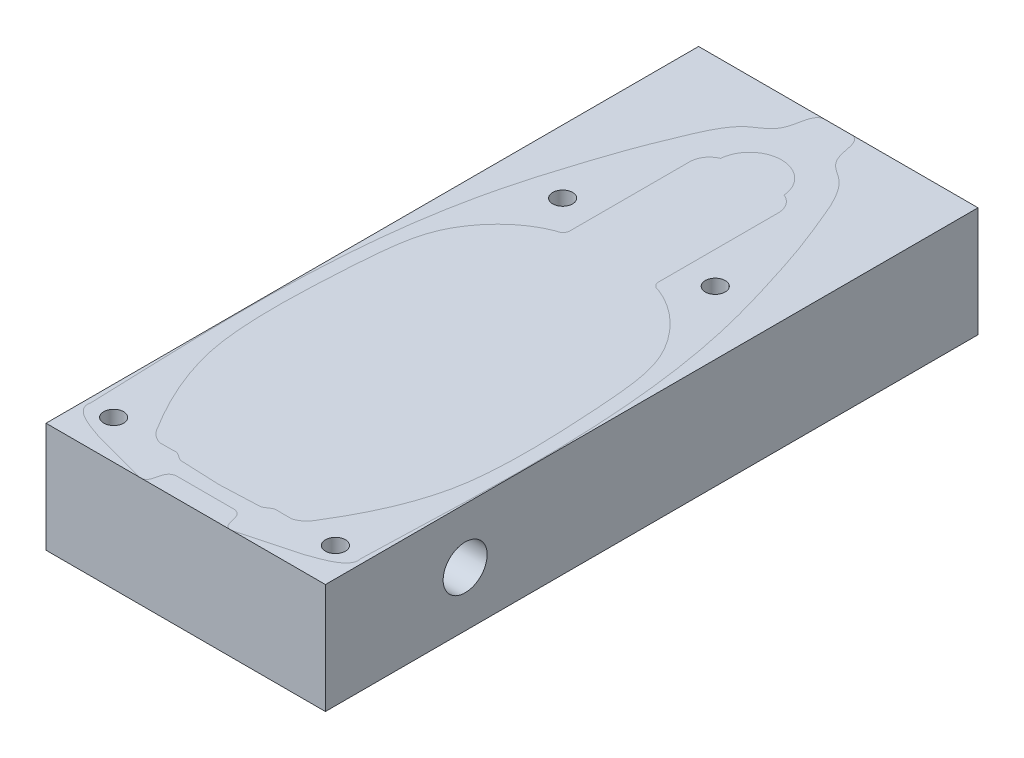
from build123d import *

# Parameters (mm, degrees)
SKETCH1_R           = 3.624738262
BOSS_EXTRUDE1_DEPTH = 39.99992
CUT_EXTRUDE1_DEPTH  = 12.7
SKETCH2_5_R         = 8
CUT_EXTRUDE2_DEPTH  = 32
SKETCH2_6_R         = 8
CUT_EXTRUDE3_DEPTH  = 102.6
CUT_EXTRUDE4_DEPTH  = 6.35


with BuildPart() as part:
    # Sketch1 → Boss-Extrude1 (new body)
    with BuildSketch(Plane(origin=(0, 0, 0), x_dir=(1, 0, 0), z_dir=(0, 1, 0))):
        with BuildLine():
            add(Edge.make_bspline(
                [(-5.102919532, 217.442534033), (-6.772186373, 217.270668093), (-8.307034074, 214.419403759), (-8.818468152, 209.809743179), (-10.450311171, 205.542036855), (-13.988349159, 202.878315551), (-17.135052097, 200.878659029), (-21.922509673, 195.198487494), (-25.105344828, 187.023597167), (-30.549633993, 174.097860197), (-35.960133295, 157.773461946), (-44.738307888, 128.665983431), (-52.530859765, 73.643219076), (-50.064387697, 26.1166546), (-49.077139095, -5.292317253)],
                knots=[0.002425274, 0.002425274, 0.002425274, 0.002425274, 0.022096851, 0.039559354, 0.063258598, 0.077264421, 0.095563037, 0.110967211, 0.171488249, 0.206517367, 0.29130997, 0.391743327, 0.59645674, 1, 1, 1, 1], degree=3))
            Line((-5.102919532, 217.442534033), (-50.8, 217.442534033))
            Line((-50.8, 217.442534033), (-50.8, -19.841855411))
            Line((-50.8, -19.841855411), (-16.3294738, -19.841855411))
            add(Edge.make_bspline(
                [(-18.385240054, -19.414944059), (-17.545507284, -19.711304849), (-16.873048404, -19.841855249), (-16.3294738, -19.841855411)],
                knots=[0, 0, 0, 0, 0.124003814, 0.124003814, 0.124003814, 0.124003814], degree=3))
            add(Edge.make_bspline(
                [(-37.41909493, -14.341890116), (-18.385240054, -19.414944059)],
                knots=[0, 0, 1, 1], degree=1))
            add(Edge.make_bspline(
                [(-49.077139095, -5.292317253), (-50.568888317, -10.940069386), (-38.832871978, -13.504300857), (-37.41909493, -14.341890116)],
                knots=[0, 0, 0, 0, 1, 1, 1, 1], degree=3))
        make_face()
        with BuildLine():
            Line((50.8, 217.442534033), (5.102919532, 217.442534033))
            add(Edge.make_bspline(
                [(5.102919532, 217.442534033), (6.772186373, 217.270668093), (8.307034074, 214.419403759), (8.818468152, 209.809743179), (10.450311171, 205.542036855), (13.988349159, 202.878315551), (17.135052097, 200.878659029), (21.922509673, 195.198487494), (25.105344828, 187.023597167), (30.549633993, 174.097860197), (35.960133295, 157.773461946), (44.738307888, 128.665983431), (52.530859765, 73.643219076), (50.064387697, 26.1166546), (49.077139095, -5.292317253)],
                knots=[0.002425274, 0.002425274, 0.002425274, 0.002425274, 0.022096851, 0.039559354, 0.063258598, 0.077264421, 0.095563037, 0.110967211, 0.171488249, 0.206517367, 0.29130997, 0.391743327, 0.59645674, 1, 1, 1, 1], degree=3))
            add(Edge.make_bspline(
                [(49.077139095, -5.292317253), (50.568888317, -10.940069386), (38.832871978, -13.504300857), (37.41909493, -14.341890116)],
                knots=[0, 0, 0, 0, 1, 1, 1, 1], degree=3))
            add(Edge.make_bspline(
                [(37.41909493, -14.341890116), (18.385240054, -19.414944059)],
                knots=[0, 0, 1, 1], degree=1))
            add(Edge.make_bspline(
                [(18.385240054, -19.414944059), (17.545506772, -19.71130503), (16.873047584, -19.841855409), (16.329472805, -19.841855411)],
                knots=[0, 0, 0, 0, 0.12400389, 0.12400389, 0.12400389, 0.12400389], degree=3))
            Line((16.329472805, -19.841855411), (50.8, -19.841855411))
            Line((50.8, -19.841855411), (50.8, 217.442534033))
        make_face()
        with BuildLine():
            Line((4.445513057, 217.442534033), (-4.445513057, 217.442534033))
            Line((-4.445513057, 217.442534033), (-5.102919532, 217.442534033))
            add(Edge.make_bspline(
                [(-5.102919532, 217.442534033), (-6.772186373, 217.270668093), (-8.307034074, 214.419403759), (-8.818468152, 209.809743179), (-10.450311171, 205.542036855), (-13.988349159, 202.878315551), (-17.135052097, 200.878659029), (-21.922509673, 195.198487494), (-25.105344828, 187.023597167), (-30.549633993, 174.097860197), (-35.960133295, 157.773461946), (-44.738307888, 128.665983431), (-52.530859765, 73.643219076), (-50.064387697, 26.1166546), (-49.077139095, -5.292317253)],
                knots=[0.002425274, 0.002425274, 0.002425274, 0.002425274, 0.022096851, 0.039559354, 0.063258598, 0.077264421, 0.095563037, 0.110967211, 0.171488249, 0.206517367, 0.29130997, 0.391743327, 0.59645674, 1, 1, 1, 1], degree=3))
            add(Edge.make_bspline(
                [(-49.077139095, -5.292317253), (-50.568888317, -10.940069386), (-38.832871978, -13.504300857), (-37.41909493, -14.341890116)],
                knots=[0, 0, 0, 0, 1, 1, 1, 1], degree=3))
            add(Edge.make_bspline(
                [(-37.41909493, -14.341890116), (-18.385240054, -19.414944059)],
                knots=[0, 0, 1, 1], degree=1))
            add(Edge.make_bspline(
                [(-18.385240054, -19.414944059), (-17.545507284, -19.711304849), (-16.873048404, -19.841855249), (-16.3294738, -19.841855411)],
                knots=[0, 0, 0, 0, 0.124003814, 0.124003814, 0.124003814, 0.124003814], degree=3))
            add(Edge.make_bspline(
                [(-16.3294738, -19.841855411), (-12.489517066, -19.841856555), (-15.081386178, -13.326893789), (-10.571420329, -12.727383648)],
                knots=[0.124003814, 0.124003814, 0.124003814, 0.124003814, 1, 1, 1, 1], degree=3))
            Line((-10.571420329, -12.727383648), (10.571420329, -12.727383648))
            add(Edge.make_bspline(
                [(16.329472805, -19.841855411), (12.489517514, -19.84185543), (15.081385788, -13.326893737), (10.571420329, -12.727383648)],
                knots=[0.12400389, 0.12400389, 0.12400389, 0.12400389, 1, 1, 1, 1], degree=3))
            add(Edge.make_bspline(
                [(18.385240054, -19.414944059), (17.545506772, -19.71130503), (16.873047584, -19.841855409), (16.329472805, -19.841855411)],
                knots=[0, 0, 0, 0, 0.12400389, 0.12400389, 0.12400389, 0.12400389], degree=3))
            add(Edge.make_bspline(
                [(37.41909493, -14.341890116), (18.385240054, -19.414944059)],
                knots=[0, 0, 1, 1], degree=1))
            add(Edge.make_bspline(
                [(49.077139095, -5.292317253), (50.568888317, -10.940069386), (38.832871978, -13.504300857), (37.41909493, -14.341890116)],
                knots=[0, 0, 0, 0, 1, 1, 1, 1], degree=3))
            add(Edge.make_bspline(
                [(5.102919532, 217.442534033), (6.772186373, 217.270668093), (8.307034074, 214.419403759), (8.818468152, 209.809743179), (10.450311171, 205.542036855), (13.988349159, 202.878315551), (17.135052097, 200.878659029), (21.922509673, 195.198487494), (25.105344828, 187.023597167), (30.549633993, 174.097860197), (35.960133295, 157.773461946), (44.738307888, 128.665983431), (52.530859765, 73.643219076), (50.064387697, 26.1166546), (49.077139095, -5.292317253)],
                knots=[0.002425274, 0.002425274, 0.002425274, 0.002425274, 0.022096851, 0.039559354, 0.063258598, 0.077264421, 0.095563037, 0.110967211, 0.171488249, 0.206517367, 0.29130997, 0.391743327, 0.59645674, 1, 1, 1, 1], degree=3))
            Line((5.102919532, 217.442534033), (4.445513057, 217.442534033))
        make_face()
        with Locations((-40.32062291, -5.716007511)):
            Circle(SKETCH1_R, mode=Mode.SUBTRACT)
        with Locations((40.32062291, -5.716007511)):
            Circle(SKETCH1_R, mode=Mode.SUBTRACT)
        with BuildLine():
            Line((-16.104538235, 135.534945765), (-16.104538235, 179.489872376))
            ThreePointArc((-16.104538235, 179.489872376), (-14.856838211, 183.535157802), (-11.547275104, 186.174832321))
            ThreePointArc((-11.547275104, 186.174832321), (0, 196.808755074), (11.547275104, 186.174832321))
            ThreePointArc((11.547275104, 186.174832321), (14.856838211, 183.535157802), (16.104538235, 179.489872376))
            Line((16.104538235, 179.489872376), (16.104538235, 135.534945765))
            ThreePointArc((16.104538235, 135.534945765), (17.083827395, 134.03150708), (18.744661517, 133.352562929))
            add(Edge.make_bspline(
                [(18.744661517, 133.352562929), (24.072442652, 131.2924301), (32.602974887, 124.998790744), (41.637553202, 111.373856913), (43.965647761, 96.124513555), (45.050077329, 79.52972727), (45.881637514, 62.808624531), (45.602911581, 47.686022443), (43.216376699, 25.657328118), (35.94711566, 10.098547862), (28.989754302, -1.112627042)],
                knots=[0, 0, 0, 0, 0.114751729, 0.21197508, 0.323247979, 0.422594947, 0.550935393, 0.662789023, 0.729556884, 1, 1, 1, 1], degree=3))
            add(Edge.make_bspline(
                [(28.989754302, -1.112627042), (27.974155949, -3.099869503), (26.103151689, -4.730794842), (23.929709743, -5.292317253)],
                knots=[0, 0, 0, 0, 1, 1, 1, 1], degree=3))
            Line((23.929709743, -5.292317253), (19.001271831, -5.292317253))
            add(Edge.make_bspline(
                [(19.001271831, -5.292317253), (16.993440786, -4.847564795), (16.076709154, -6.856231256), (14.305888181, -7.108132642)],
                knots=[0, 0, 0, 0, 1, 1, 1, 1], degree=3))
            Line((14.305888181, -7.108132642), (0, -7.713404439))
            Line((0, -7.713404439), (-14.305888181, -7.108132642))
            add(Edge.make_bspline(
                [(-19.001271831, -5.292317253), (-16.993440786, -4.847564795), (-16.076709154, -6.856231256), (-14.305888181, -7.108132642)],
                knots=[0, 0, 0, 0, 1, 1, 1, 1], degree=3))
            Line((-19.001271831, -5.292317253), (-23.929709743, -5.292317253))
            add(Edge.make_bspline(
                [(-28.989754302, -1.112627042), (-27.974155949, -3.099869503), (-26.103151689, -4.730794842), (-23.929709743, -5.292317253)],
                knots=[0, 0, 0, 0, 1, 1, 1, 1], degree=3))
            add(Edge.make_bspline(
                [(-18.744661517, 133.352562929), (-24.072442652, 131.2924301), (-32.602974887, 124.998790744), (-41.637553202, 111.373856913), (-43.965647761, 96.124513555), (-45.050077329, 79.52972727), (-45.881637514, 62.808624531), (-45.602911581, 47.686022443), (-43.216376699, 25.657328118), (-35.94711566, 10.098547862), (-28.989754302, -1.112627042)],
                knots=[0, 0, 0, 0, 0.114751729, 0.21197508, 0.323247979, 0.422594947, 0.550935393, 0.662789023, 0.729556884, 1, 1, 1, 1], degree=3))
            ThreePointArc((-18.744661517, 133.352562929), (-17.083827395, 134.03150708), (-16.104538235, 135.534945765))
        make_face(mode=Mode.SUBTRACT)
        with Locations((-27.744990659, 144.952451062)):
            Circle(SKETCH1_R, mode=Mode.SUBTRACT)
        with Locations((27.744990659, 144.952451062)):
            Circle(SKETCH1_R, mode=Mode.SUBTRACT)
        with BuildLine():
            add(Edge.make_bspline(
                [(18.744661517, 133.352562929), (24.072442652, 131.2924301), (32.602974887, 124.998790744), (41.637553202, 111.373856913), (43.965647761, 96.124513555), (45.050077329, 79.52972727), (45.881637514, 62.808624531), (45.602911581, 47.686022443), (43.216376699, 25.657328118), (35.94711566, 10.098547862), (28.989754302, -1.112627042)],
                knots=[0, 0, 0, 0, 0.114751729, 0.21197508, 0.323247979, 0.422594947, 0.550935393, 0.662789023, 0.729556884, 1, 1, 1, 1], degree=3))
            add(Edge.make_bspline(
                [(28.989754302, -1.112627042), (27.974155949, -3.099869503), (26.103151689, -4.730794842), (23.929709743, -5.292317253)],
                knots=[0, 0, 0, 0, 1, 1, 1, 1], degree=3))
            Line((23.929709743, -5.292317253), (19.001271831, -5.292317253))
            add(Edge.make_bspline(
                [(19.001271831, -5.292317253), (16.993440786, -4.847564795), (16.076709154, -6.856231256), (14.305888181, -7.108132642)],
                knots=[0, 0, 0, 0, 1, 1, 1, 1], degree=3))
            Line((14.305888181, -7.108132642), (0, -7.713404439))
            Line((0, -7.713404439), (-14.305888181, -7.108132642))
            add(Edge.make_bspline(
                [(-19.001271831, -5.292317253), (-16.993440786, -4.847564795), (-16.076709154, -6.856231256), (-14.305888181, -7.108132642)],
                knots=[0, 0, 0, 0, 1, 1, 1, 1], degree=3))
            Line((-19.001271831, -5.292317253), (-23.929709743, -5.292317253))
            add(Edge.make_bspline(
                [(-28.989754302, -1.112627042), (-27.974155949, -3.099869503), (-26.103151689, -4.730794842), (-23.929709743, -5.292317253)],
                knots=[0, 0, 0, 0, 1, 1, 1, 1], degree=3))
            add(Edge.make_bspline(
                [(-18.744661517, 133.352562929), (-24.072442652, 131.2924301), (-32.602974887, 124.998790744), (-41.637553202, 111.373856913), (-43.965647761, 96.124513555), (-45.050077329, 79.52972727), (-45.881637514, 62.808624531), (-45.602911581, 47.686022443), (-43.216376699, 25.657328118), (-35.94711566, 10.098547862), (-28.989754302, -1.112627042)],
                knots=[0, 0, 0, 0, 0.114751729, 0.21197508, 0.323247979, 0.422594947, 0.550935393, 0.662789023, 0.729556884, 1, 1, 1, 1], degree=3))
            ThreePointArc((-18.744661517, 133.352562929), (-17.083827395, 134.03150708), (-16.104538235, 135.534945765))
            Line((-16.104538235, 135.534945765), (-16.104538235, 179.489872376))
            ThreePointArc((-16.104538235, 179.489872376), (-14.856838211, 183.535157802), (-11.547275104, 186.174832321))
            ThreePointArc((-11.547275104, 186.174832321), (0, 196.808755074), (11.547275104, 186.174832321))
            ThreePointArc((11.547275104, 186.174832321), (14.856838211, 183.535157802), (16.104538235, 179.489872376))
            Line((16.104538235, 179.489872376), (16.104538235, 135.534945765))
            ThreePointArc((16.104538235, 135.534945765), (17.083827395, 134.03150708), (18.744661517, 133.352562929))
        make_face()
        with BuildLine():
            add(Edge.make_bspline(
                [(-16.3294738, -19.841855411), (-12.489517066, -19.841856555), (-15.081386178, -13.326893789), (-10.571420329, -12.727383648)],
                knots=[0.124003814, 0.124003814, 0.124003814, 0.124003814, 1, 1, 1, 1], degree=3))
            Line((-16.3294738, -19.841855411), (16.329472805, -19.841855411))
            add(Edge.make_bspline(
                [(16.329472805, -19.841855411), (12.489517514, -19.84185543), (15.081385788, -13.326893737), (10.571420329, -12.727383648)],
                knots=[0.12400389, 0.12400389, 0.12400389, 0.12400389, 1, 1, 1, 1], degree=3))
            Line((10.571420329, -12.727383648), (-10.571420329, -12.727383648))
        make_face()
    extrude(amount=-BOSS_EXTRUDE1_DEPTH)

    # Sketch2 → Cut-Extrude1 (cut)
    with BuildSketch(Plane.ZY.offset(50.8)):
        with BuildLine():
            ThreePointArc((-44.393173431, -9.314971157), (-41.643173431, -6.564971157), (-44.393173431, -3.814971157))
            ThreePointArc((-44.393173431, -3.814971157), (-47.143173431, -6.564971157), (-44.393173431, -9.314971157))
        make_face()
        with BuildLine():
            ThreePointArc((-49.958144589, -22.75), (-47.208144589, -20), (-49.958144589, -17.25))
            ThreePointArc((-49.958144589, -17.25), (-52.708144589, -20), (-49.958144589, -22.75))
        make_face()
        with BuildLine():
            ThreePointArc((-44.393173431, -36.185028843), (-41.643173431, -33.435028843), (-44.393173431, -30.685028843))
            ThreePointArc((-44.393173431, -30.685028843), (-47.143173431, -33.435028843), (-44.393173431, -36.185028843))
        make_face()
        with BuildLine():
            ThreePointArc((-17.523115746, -36.185028843), (-14.773115746, -33.435028843), (-17.523115746, -30.685028843))
            ThreePointArc((-17.523115746, -30.685028843), (-20.273115746, -33.435028843), (-17.523115746, -36.185028843))
        make_face()
        with BuildLine():
            ThreePointArc((-11.958144589, -22.75), (-9.208144589, -20), (-11.958144589, -17.25))
            ThreePointArc((-11.958144589, -17.25), (-14.708144589, -20), (-11.958144589, -22.75))
        make_face()
        with BuildLine():
            ThreePointArc((-17.523115746, -9.314971157), (-14.773115746, -6.564971157), (-17.523115746, -3.814971157))
            ThreePointArc((-17.523115746, -3.814971157), (-20.273115746, -6.564971157), (-17.523115746, -9.314971157))
        make_face()
    extrude(amount=-CUT_EXTRUDE1_DEPTH, mode=Mode.SUBTRACT)

    # Sketch2_5 → Cut-Extrude2 (cut)
    with BuildSketch(Plane.ZY.offset(50.8)):
        with BuildLine():
            ThreePointArc((-30.958144589, -6), (-44.958144589, -20), (-30.958144589, -34))
            ThreePointArc((-30.958144589, -34), (-16.958144589, -20), (-30.958144589, -6))
        make_face()
        with Locations((-30.958144589, -20)):
            Circle(SKETCH2_5_R)
    extrude(amount=-CUT_EXTRUDE2_DEPTH, mode=Mode.SUBTRACT)

    # Sketch2_6 → Cut-Extrude3 (cut, through all)
    with BuildSketch(Plane.ZY.offset(50.8)):
        with Locations((-30.958144589, -20)):
            Circle(SKETCH2_6_R)
    extrude(amount=-CUT_EXTRUDE3_DEPTH, mode=Mode.SUBTRACT)

    # Sketch3 → Cut-Extrude4 (cut)
    with BuildSketch(Plane.XZ.offset(39.99992)):
        with BuildLine():
            ThreePointArc((-44.218963095, -53.558144589), (-42.118963095, -51.458144589), (-44.218963095, -49.358144589))
            ThreePointArc((-44.218963095, -49.358144589), (-46.318963095, -51.458144589), (-44.218963095, -53.558144589))
        make_face()
        with BuildLine():
            ThreePointArc((-18.218963095, -53.558144589), (-16.118963095, -51.458144589), (-18.218963095, -49.358144589))
            ThreePointArc((-18.218963095, -49.358144589), (-20.318963095, -51.458144589), (-18.218963095, -53.558144589))
        make_face()
        with BuildLine():
            ThreePointArc((-18.218963095, -12.558144589), (-16.118963095, -10.458144589), (-18.218963095, -8.358144589))
            ThreePointArc((-18.218963095, -8.358144589), (-20.318963095, -10.458144589), (-18.218963095, -12.558144589))
        make_face()
        with BuildLine():
            ThreePointArc((-44.218963095, -12.558144589), (-42.118963095, -10.458144589), (-44.218963095, -8.358144589))
            ThreePointArc((-44.218963095, -8.358144589), (-46.318963095, -10.458144589), (-44.218963095, -12.558144589))
        make_face()
    extrude(amount=-CUT_EXTRUDE4_DEPTH, mode=Mode.SUBTRACT)


solid = part.part
